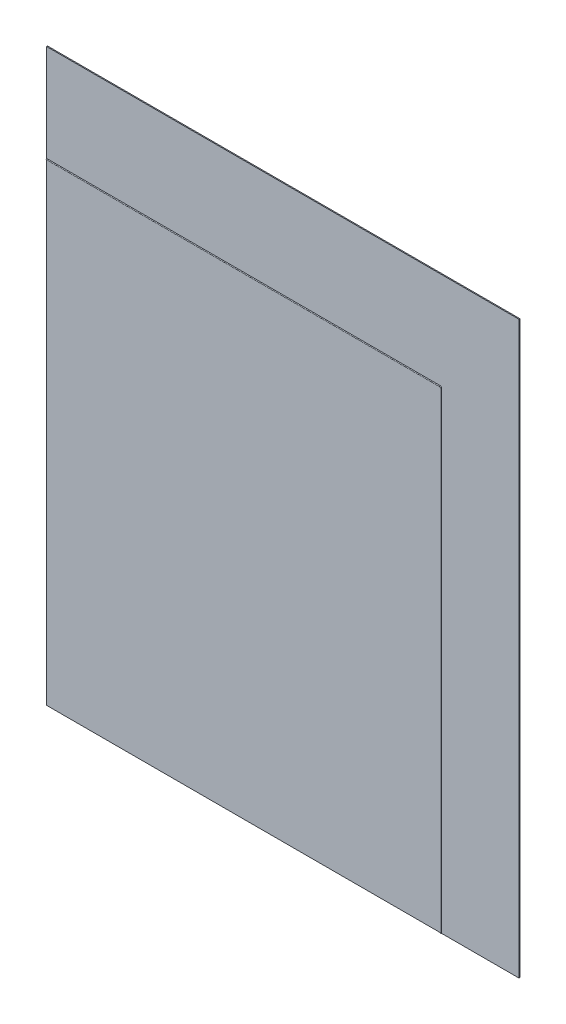
from build123d import *

# Parameters (mm, degrees)
SKETCH1_W           = 1219.2
SKETCH1_H           = 1473.2
BOSS_EXTRUDE1_DEPTH = 2.54
SWEEP1_PROFILE_R    = 1.27


with BuildPart() as part:
    # Sketch1 → Boss-Extrude1 (new body)
    with BuildSketch(Plane.XY):
        Rectangle(SKETCH1_W, SKETCH1_H)
    extrude(amount=BOSS_EXTRUDE1_DEPTH)

    # Sweep1: sweep along a path in Sketch2
    with BuildLine(Plane.XY.offset(2.54)) as sweep1_path:
        Line((408.94, -736.6), (408.94, 482.6))
        ThreePointArc((408.94, 482.6), (408.196051224, 484.396051224), (406.4, 485.14))
        Line((406.4, 485.14), (-609.6, 485.14))
    # Sweep1 profile (on start of the path) → Sweep1 (sweep)
    with BuildSketch(Plane(origin=(408.94, -736.6, 2.54), x_dir=(0, 0, 1), z_dir=(0, 1, 0))):
        Circle(SWEEP1_PROFILE_R)
    sweep(path=sweep1_path.line)


solid = part.part
